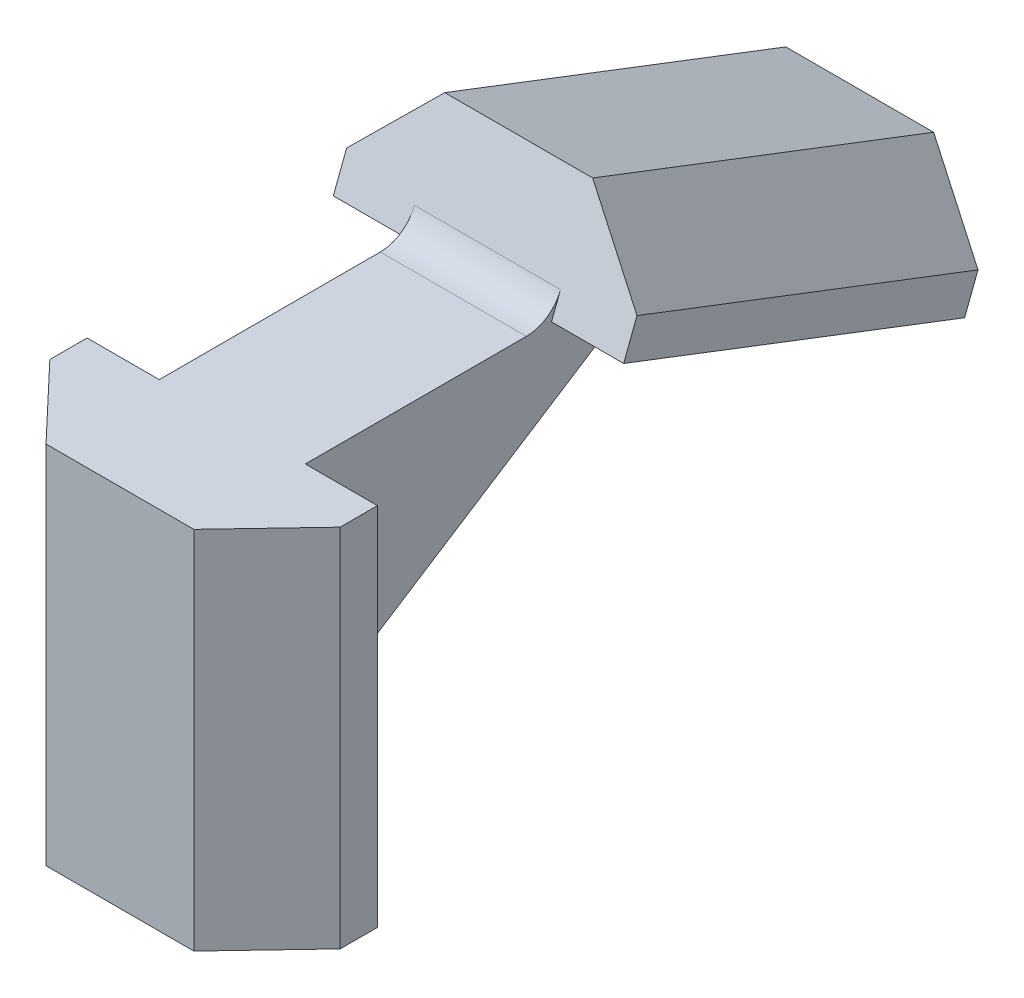
from build123d import *

# Parameters (mm, degrees)
BOSS_EXTRUDE1_DEPTH = 20
BOSS_EXTRUDE3_DEPTH = 4
SKETCH11_W          = 8
SKETCH11_H          = 4.067153682
BOSS_EXTRUDE8_DEPTH = 1
BOSS_EXTRUDE7_DEPTH = 20
FILLET1_R           = 2


with BuildPart() as part:
    # Sketch1 → Boss-Extrude1 (new body)
    with BuildSketch(Plane(origin=(0, 0, 0), x_dir=(1, 0, 0), z_dir=(0, 1, 0))):
        Polygon((7.95, 0), (7.95, -2.04), (4.048, -6.152414984), (-4.048, -6.152414984), (-7.95, -2.04), (-7.95, 0), align=None)
    extrude(amount=-BOSS_EXTRUDE1_DEPTH)

    # Sketch4 → Boss-Extrude3 (add, symmetric)
    with BuildSketch(Plane(origin=(0, 0, 0), x_dir=(0, 0, -1), z_dir=(1, 0, 0))):
        Polygon((13.481068451, 0), (0, 0), (0, -12.539693486), (17.27808352, -1.457537526), align=None)
    extrude(amount=BOSS_EXTRUDE3_DEPTH, both=True)

    # Sketch11 → Boss-Extrude8 (add)
    with BuildSketch(Plane(origin=(0, 4.510297753, -1.731341095), x_dir=(1, 0, 0), z_dir=(0, 0.933580426, -0.35836795))):
        with Locations((0, 14.619238475)):
            Rectangle(SKETCH11_W, SKETCH11_H)
    extrude(amount=BOSS_EXTRUDE8_DEPTH)

    # Sketch10 → Boss-Extrude7 (add)
    with BuildSketch(Plane(origin=(0, -4.510297753, -11.749727356), x_dir=(1, 0, 0), z_dir=(0, 0.35836795, 0.933580426))):
        Polygon((-7.95, 4.831182858), (-7.95, 6.871182858), (-4.048, 10.983597842), (4.048, 10.983597842), (7.95, 6.871182858), (7.95, 4.831182858), align=None)
    extrude(amount=-BOSS_EXTRUDE7_DEPTH)

    # Fillet1
    fillet1_edges = [part.edges().sort_by_distance(p)[0] for p in [
        (0, -12.539693486, 0),
        (0, -1.457537526, -17.27808352),
        (0, 0, -13.481068451),
    ]]
    fillet(fillet1_edges, radius=FILLET1_R)


solid = part.part
